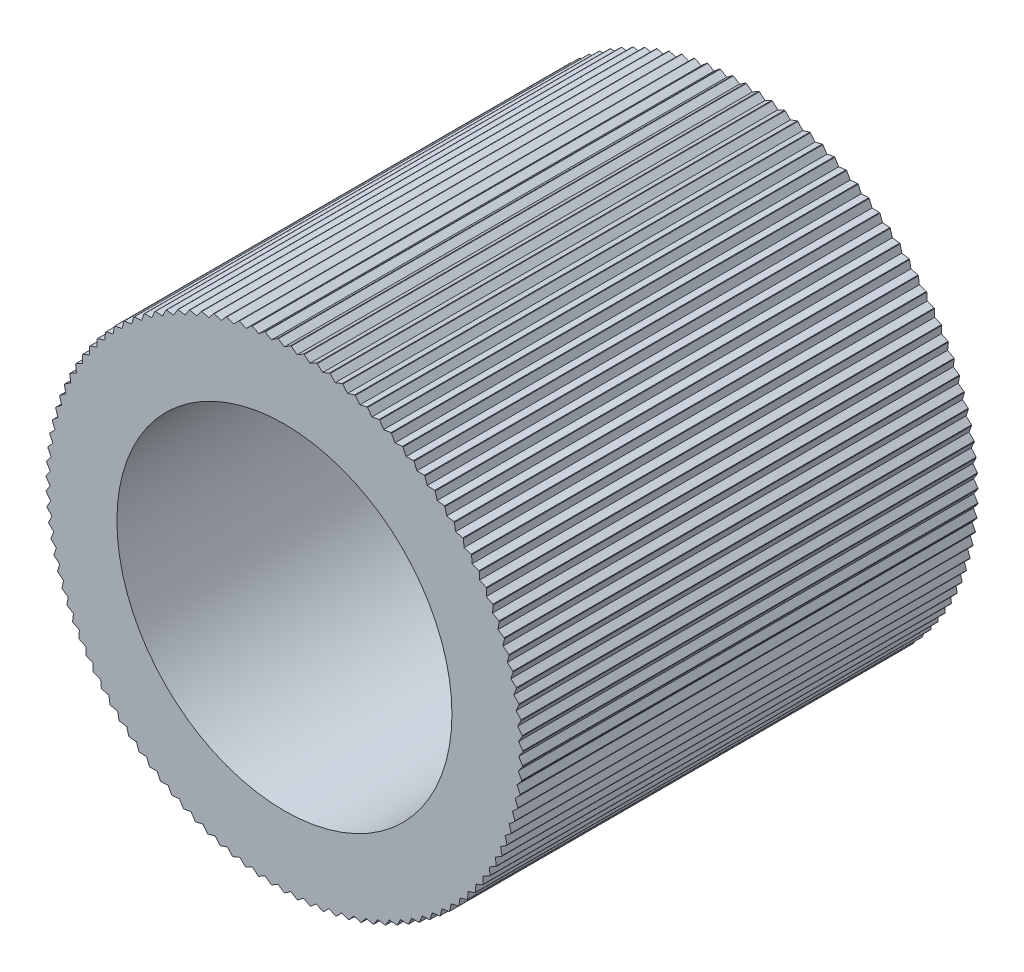
from build123d import *

# Parameters (mm, degrees)
CROQUIS1_R                                     = 3.85
SALIENTE_EXTRUIR1_DEPTH                        = 7.35
PERFORADOR_PARA_ROSCAR_PARA_MACHO_DE_ROS_D     = 5.4102
PERFORADOR_PARA_ROSCAR_PARA_MACHO_DE_ROS_DEPTH = 7.35
CORTAR_EXTRUIR1_DEPTH                          = 7.35
MATRIZC1_COUNT                                 = 115


with BuildPart() as part:
    # Croquis1 → Saliente-Extruir1 (new body)
    with BuildSketch(Plane.XY):
        Circle(CROQUIS1_R)
    extrude(amount=SALIENTE_EXTRUIR1_DEPTH)

    # Perforador para roscar para macho de roscar para 1/4-281
    with Locations(Plane.XY.offset(7.35)):
        with Locations((0, 0)):
            Hole(PERFORADOR_PARA_ROSCAR_PARA_MACHO_DE_ROS_D / 2, depth=PERFORADOR_PARA_ROSCAR_PARA_MACHO_DE_ROS_DEPTH)

    # Croquis4 → Cortar-Extruir1 (cut)
    with BuildSketch(Plane.XY.offset(7.35)):
        with BuildLine():
            Line((-0.1, 3.84870108), (0, 3.783525614))
            Line((0, 3.783525614), (0.1, 3.84870108))
            ThreePointArc((0.1, 3.84870108), (0, 3.85), (-0.1, 3.84870108))
        make_face()
    cortar_extruir1 = extrude(amount=-CORTAR_EXTRUIR1_DEPTH, mode=Mode.SUBTRACT)

    # MatrizC1: Cortar-Extruir1 ×115 about axis
    matrizc1_axis = Axis((0, 0, 0), (0, 0, 1))
    for i in range(1, MATRIZC1_COUNT):
        add(cortar_extruir1.rotate(matrizc1_axis, i * 360 / MATRIZC1_COUNT), mode=Mode.SUBTRACT)


solid = part.part
